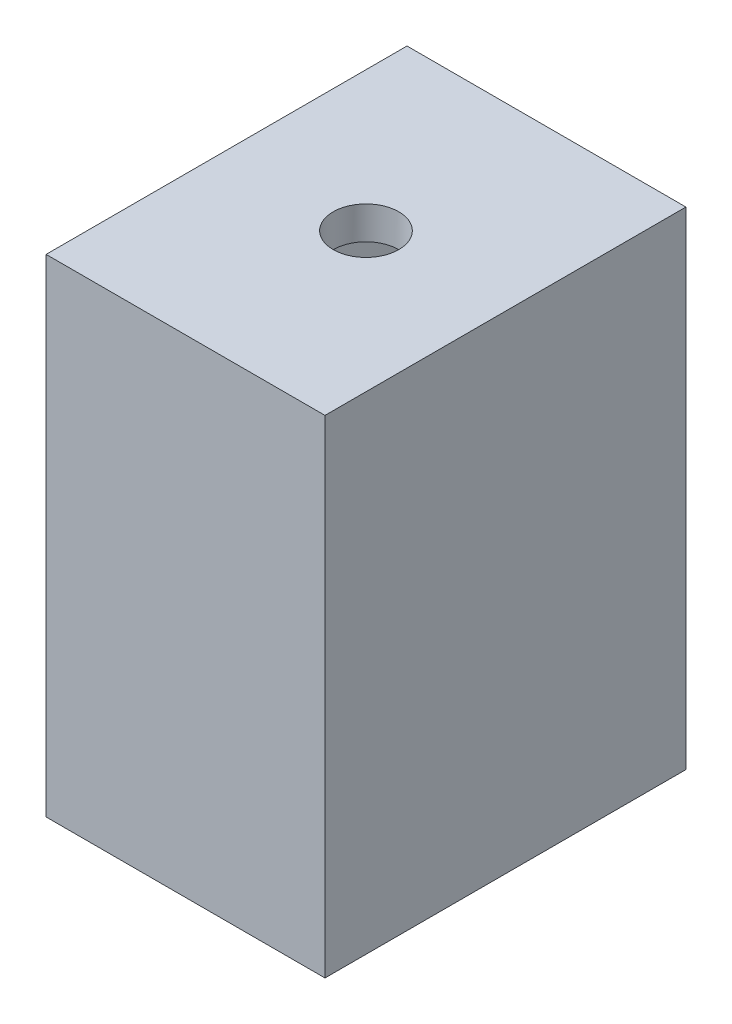
from build123d import *

# Parameters (mm, degrees)
SKETCH1_W           = 17
SKETCH1_H           = 29.7
BOSS_EXTRUDE1_DEPTH = 22
SKETCH2_R           = 2
CUT_EXTRUDE1_DEPTH  = 30.7
SKETCH3_R           = 4
CUT_EXTRUDE2_DEPTH  = 27.7
CUT_EXTRUDE4_START  = -2
SKETCH4_W           = 13
SKETCH4_H           = 18
CUT_EXTRUDE4_DEPTH  = 25.7


with BuildPart() as part:
    # Sketch1 → Boss-Extrude1 (new body)
    with BuildSketch(Plane.XY):
        with Locations((8.5, 14.85)):
            Rectangle(SKETCH1_W, SKETCH1_H)
    extrude(amount=BOSS_EXTRUDE1_DEPTH)

    # Sketch2 → Cut-Extrude1 (cut, through all)
    with BuildSketch(Plane(origin=(0, 29.7, 0), x_dir=(1, 0, 0), z_dir=(0, 1, 0))):
        with Locations((8.5, -11)):
            Circle(SKETCH2_R)
    extrude(amount=-CUT_EXTRUDE1_DEPTH, mode=Mode.SUBTRACT)

    # Sketch3 → Cut-Extrude2 (cut)
    with BuildSketch(Plane.XZ):
        with Locations((8.5, 11)):
            Circle(SKETCH3_R)
    extrude(amount=-CUT_EXTRUDE2_DEPTH, mode=Mode.SUBTRACT)

    # Sketch4 → Cut-Extrude4 (cut)
    with BuildSketch(Plane.XZ.offset(CUT_EXTRUDE4_START)):
        with Locations((8.5, 11)):
            Rectangle(SKETCH4_W, SKETCH4_H)
    extrude(amount=-CUT_EXTRUDE4_DEPTH, mode=Mode.SUBTRACT)


solid = part.part
